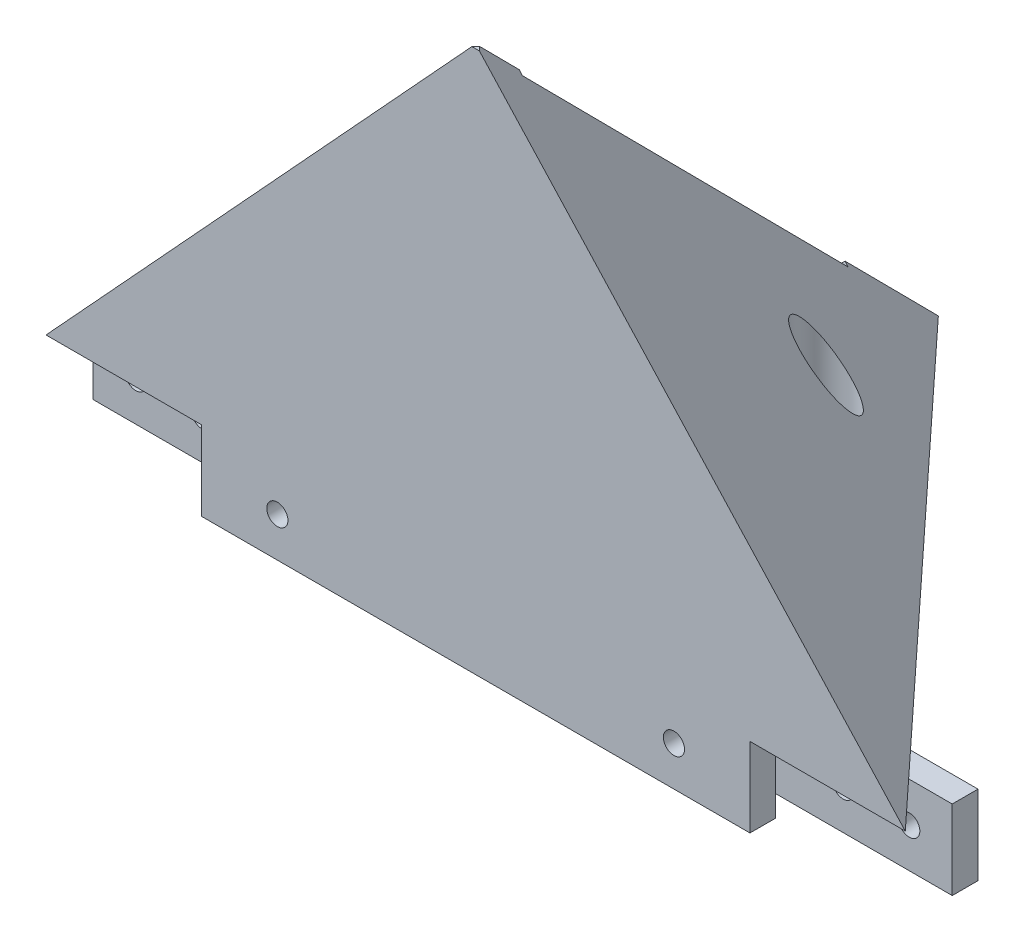
from build123d import *

# Parameters (mm, degrees)
BOSS_EXTRUDE1_DEPTH = 70
DRAFT3_ANGLE        = -34
SKETCH2_R           = 4
CUT_EXTRUDE1_DEPTH  = 70
CUT_EXTRUDE3_START  = 64.5
CUT_EXTRUDE3_DEPTH  = 1
SKETCH6_W           = 130
SKETCH6_H           = 3.9
BOSS_EXTRUDE2_DEPTH = 12
SKETCH7_R           = 1.6
CUT_EXTRUDE4_DEPTH  = 70
CUT_EXTRUDE5_START  = -6
SKETCH7_3_W         = 23.5
SKETCH7_3_H         = 12
SKETCH7_3_R         = 1.6
CUT_EXTRUDE5_DEPTH  = 70


with BuildPart() as part:
    # Sketch1 → Boss-Extrude1 (new body)
    with BuildSketch(Plane(origin=(0, 0, 0), x_dir=(1, 0, 0), z_dir=(0, 1, 0))):
        Polygon((65, 0), (0, -70), (130, -70), align=None)
    extrude(amount=BOSS_EXTRUDE1_DEPTH)

    # Draft3
    draft3_faces = [part.faces().sort_by_distance(p)[0] for p in [
        (97.5, 35, 35),
        (32.5, 35, 35),
    ]]
    draft(draft3_faces, Plane(origin=(0, 0, 0), x_dir=(0, 0, -1), z_dir=(0, -1, 0)), DRAFT3_ANGLE)

    # Sketch2 → Cut-Extrude1 (cut)
    with BuildSketch(Plane.XZ):
        with Locations((51, 31)):
            Circle(SKETCH2_R)
        with Locations((79, 31)):
            Circle(SKETCH2_R)
    extrude(amount=-CUT_EXTRUDE1_DEPTH, mode=Mode.SUBTRACT)

    # Sketch5 → Cut-Extrude3 (cut)
    with BuildSketch(Plane(origin=(0, 0, 0), x_dir=(0, 0, -1), z_dir=(1, 0, 0)).offset(CUT_EXTRUDE3_START)):
        Polygon((-14.079975623, 14.204023601), (-63.359890305, 63.918106202), (-66.397363247, 52.777769966), (-17.117448565, 3.063687364), align=None)
    extrude(amount=CUT_EXTRUDE3_DEPTH, mode=Mode.SUBTRACT)

    # Sketch6 → Boss-Extrude2 (add)
    with BuildSketch(Plane.XZ):
        with Locations((65, 68.05)):
            Rectangle(SKETCH6_W, SKETCH6_H)
        with Locations((65, 60.95)):
            Rectangle(SKETCH6_W, SKETCH6_H)
    extrude(amount=BOSS_EXTRUDE2_DEPTH)

    # Sketch7 → Cut-Extrude4 (cut)
    with BuildSketch(Plane(origin=(0, 0, 59), x_dir=(-1, 0, 0), z_dir=(0, 0, -1))):
        with Locations((-95, -6)):
            Circle(SKETCH7_R)
        with Locations((-123.5, -6)):
            Circle(SKETCH7_R)
        with Locations((-113.5, -6)):
            Circle(SKETCH7_R)
        with Locations((-6.5, -6)):
            Circle(SKETCH7_R)
        with Locations((-16.5, -6)):
            Circle(SKETCH7_R)
        with Locations((-35, -6)):
            Circle(SKETCH7_R)
    extrude(amount=-CUT_EXTRUDE4_DEPTH, mode=Mode.SUBTRACT)

    # Sketch7_3 → Cut-Extrude5 (cut)
    # profile 1 of 2: a face of its own
    with BuildSketch(Plane(origin=(0, 0, 59), x_dir=(-1, 0, 0), z_dir=(0, 0, -1)).offset(CUT_EXTRUDE5_START)):
        with Locations((-118.25, -6)):
            Rectangle(SKETCH7_3_W, SKETCH7_3_H)
        with Locations((-123.5, -6)):
            Circle(SKETCH7_3_R, mode=Mode.SUBTRACT)
        with Locations((-113.5, -6)):
            Circle(SKETCH7_3_R, mode=Mode.SUBTRACT)
    # profile 2 of 2: a face of its own
    with BuildSketch(Plane(origin=(0, 0, 59), x_dir=(-1, 0, 0), z_dir=(0, 0, -1)).offset(CUT_EXTRUDE5_START)):
        with Locations((-11.75, -6)):
            Rectangle(SKETCH7_3_W, SKETCH7_3_H)
        with Locations((-16.5, -6)):
            Circle(SKETCH7_3_R, mode=Mode.SUBTRACT)
        with Locations((-6.5, -6)):
            Circle(SKETCH7_3_R, mode=Mode.SUBTRACT)
    extrude(amount=-CUT_EXTRUDE5_DEPTH, mode=Mode.SUBTRACT)


solid = part.part
